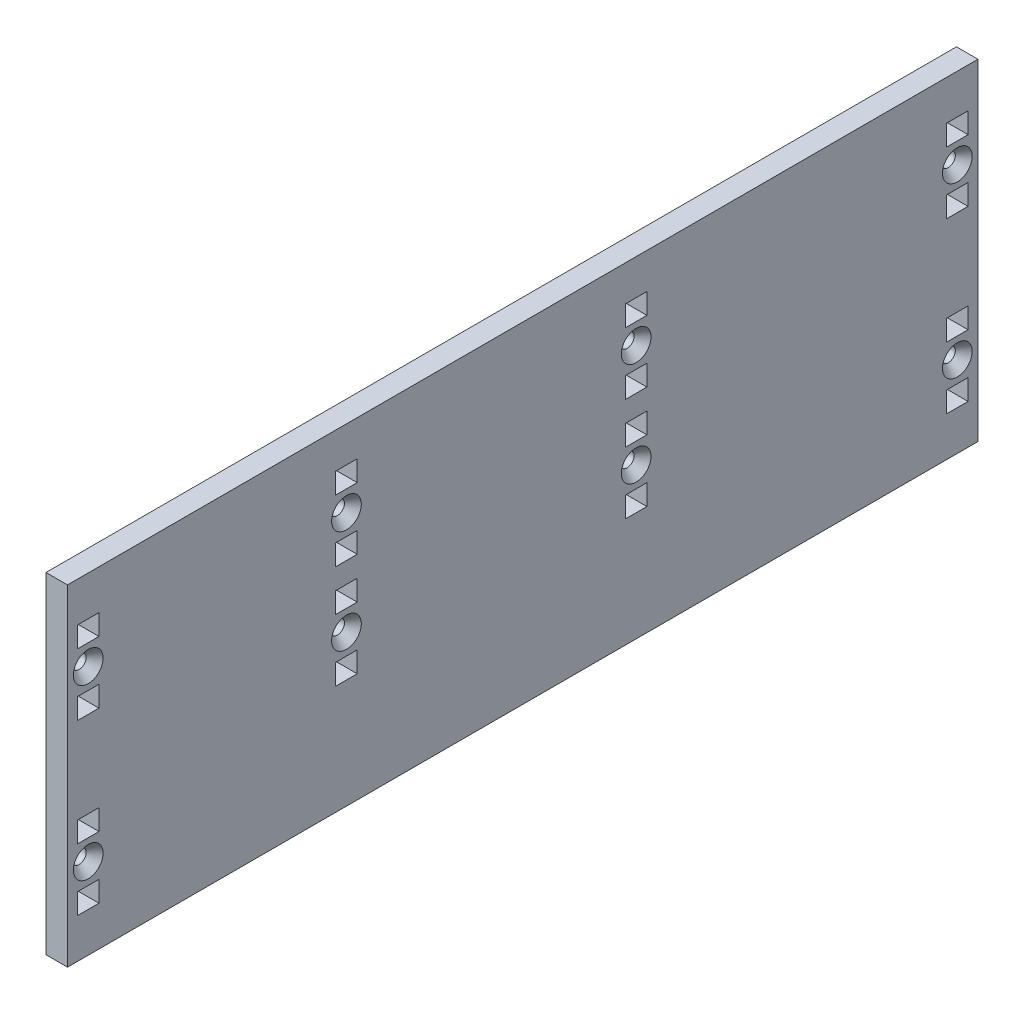
from build123d import *

# Parameters (mm, degrees)
SKETCH1_W                                         = 279.4
SKETCH1_H                                         = 101.6
SKETCH1_R                                         = 2.15265
SKETCH1_W_2                                       = 6.604
SKETCH1_H_2                                       = 6.35
BOSS_EXTRUDE1_DEPTH                               = 6.604
SKETCH2_R                                         = 2.15265
SKETCH2_W                                         = 6.604
SKETCH2_H                                         = 6.35
CUT_EXTRUDE1_DEPTH                                = 7.604
CSK_FOR_8_FLAT_HEAD_SOCKET_CAP_SCREW1_D           = 4.3053
CSK_FOR_8_FLAT_HEAD_SOCKET_CAP_SCREW1_CSINK_D     = 9.1186
CSK_FOR_8_FLAT_HEAD_SOCKET_CAP_SCREW1_CSINK_ANGLE = 82


with BuildPart() as part:
    # Sketch1 → Boss-Extrude1 (new body)
    with BuildSketch(Plane(origin=(0, 0, 0), x_dir=(0, 0, -1), z_dir=(1, 0, 0))):
        with Locations((0, -50.8)):
            Rectangle(SKETCH1_W, SKETCH1_H)
        with Locations((-133.35, -24.8793)):
            Circle(SKETCH1_R, mode=Mode.SUBTRACT)
        with Locations((-133.35, -76.7207)):
            Circle(SKETCH1_R, mode=Mode.SUBTRACT)
        with Locations((133.35, -24.8793)):
            Circle(SKETCH1_R, mode=Mode.SUBTRACT)
        with Locations((133.35, -76.720700102)):
            Circle(SKETCH1_R, mode=Mode.SUBTRACT)
        with Locations((-133.35, -34.4043)):
            Rectangle(SKETCH1_W_2, SKETCH1_H_2, mode=Mode.SUBTRACT)
        with Locations((-133.35, -15.3543)):
            Rectangle(SKETCH1_W_2, SKETCH1_H_2, mode=Mode.SUBTRACT)
        with Locations((-133.35, -86.2457)):
            Rectangle(SKETCH1_W_2, SKETCH1_H_2, mode=Mode.SUBTRACT)
        with Locations((-133.35, -67.1957)):
            Rectangle(SKETCH1_W_2, SKETCH1_H_2, mode=Mode.SUBTRACT)
        with Locations((133.35, -15.3543)):
            Rectangle(SKETCH1_W_2, SKETCH1_H_2, mode=Mode.SUBTRACT)
        with Locations((133.35, -34.4043)):
            Rectangle(SKETCH1_W_2, SKETCH1_H_2, mode=Mode.SUBTRACT)
        with Locations((133.35, -67.195700102)):
            Rectangle(SKETCH1_W_2, SKETCH1_H_2, mode=Mode.SUBTRACT)
        with Locations((133.35, -86.245700102)):
            Rectangle(SKETCH1_W_2, SKETCH1_H_2, mode=Mode.SUBTRACT)
    extrude(amount=BOSS_EXTRUDE1_DEPTH)

    # Sketch2 → Cut-Extrude1 (cut, through all)
    with BuildSketch(Plane(origin=(6.604, 0, 0), x_dir=(0, 0, -1), z_dir=(1, 0, 0))):
        with Locations((-54.102, -23.622)):
            Circle(SKETCH2_R)
        with Locations((34.798, -55.372)):
            Circle(SKETCH2_R)
        with Locations((-54.102, -55.372)):
            Circle(SKETCH2_R)
        with Locations((34.798, -23.622)):
            Circle(SKETCH2_R)
        with Locations((-54.102, -14.097)):
            Rectangle(SKETCH2_W, SKETCH2_H)
        with Locations((-54.102, -33.147)):
            Rectangle(SKETCH2_W, SKETCH2_H)
        with Locations((34.798, -45.847)):
            Rectangle(SKETCH2_W, SKETCH2_H)
        with Locations((34.798, -64.897)):
            Rectangle(SKETCH2_W, SKETCH2_H)
        with Locations((-54.102, -45.847)):
            Rectangle(SKETCH2_W, SKETCH2_H)
        with Locations((-54.102, -64.897)):
            Rectangle(SKETCH2_W, SKETCH2_H)
        with Locations((34.798, -14.097)):
            Rectangle(SKETCH2_W, SKETCH2_H)
        with Locations((34.798, -33.147)):
            Rectangle(SKETCH2_W, SKETCH2_H)
    extrude(amount=-CUT_EXTRUDE1_DEPTH, mode=Mode.SUBTRACT)

    # CSK for #8 Flat Head Socket Cap Screw1 (through all)
    with Locations(Plane(origin=(6.604, 0, 0), x_dir=(0, 0, -1), z_dir=(1, 0, 0))):
        with Locations((-133.35, -24.8793), (-133.35, -76.7207), (-54.102, -55.372), (-54.102, -23.622), (34.798, -23.622), (34.798, -55.372), (133.35, -76.720700102), (133.35, -24.8793)):
            CounterSinkHole(CSK_FOR_8_FLAT_HEAD_SOCKET_CAP_SCREW1_D / 2, CSK_FOR_8_FLAT_HEAD_SOCKET_CAP_SCREW1_CSINK_D / 2, counter_sink_angle=CSK_FOR_8_FLAT_HEAD_SOCKET_CAP_SCREW1_CSINK_ANGLE)


solid = part.part
